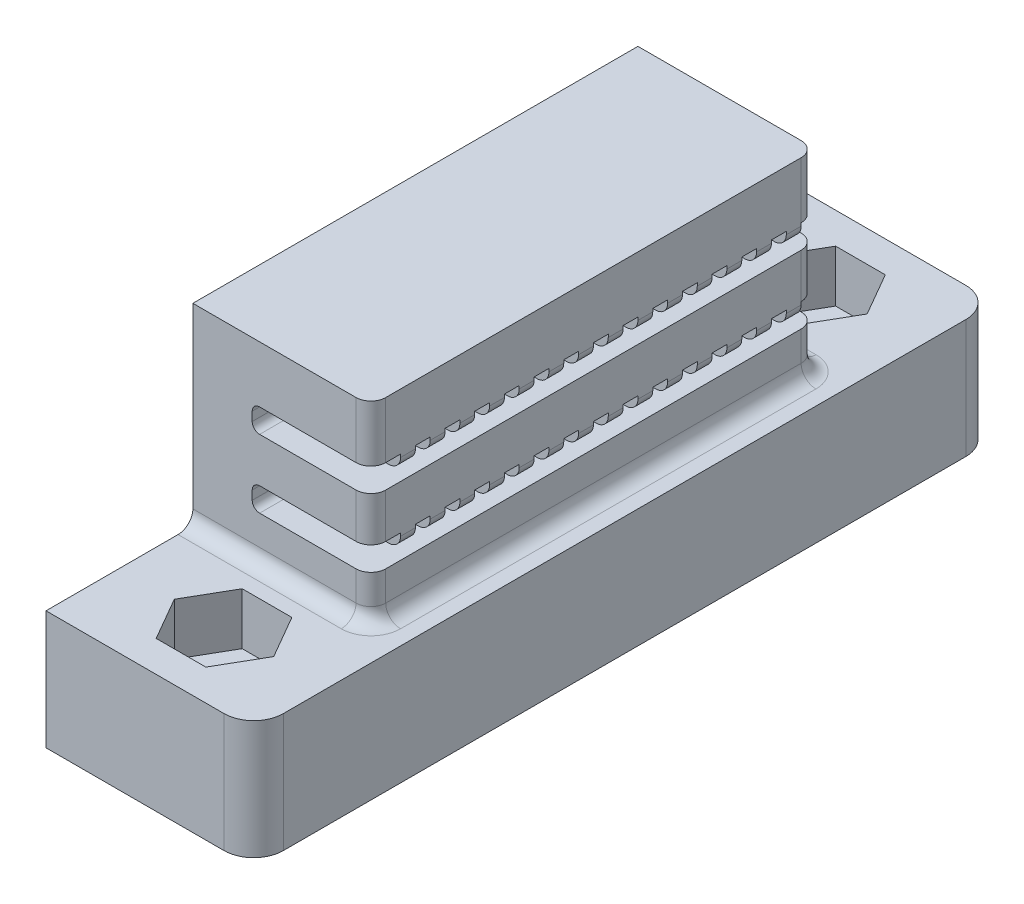
from build123d import *

# Parameters (mm, degrees)
CROQUIS1_W              = 14
CROQUIS1_H              = 50
CROQUIS1_R              = 1.55
SALIENTE_EXTRUIR1_DEPTH = 8
CORTAR_EXTRUIR1_DEPTH   = 3.5
CROQUIS3_W              = 14
CROQUIS3_H              = 30
SALIENTE_EXTRUIR3_DEPTH = 13
CORTAR_EXTRUIR2_DEPTH   = 10
CROQUIS5_W              = 30
CROQUIS5_H              = 13
CORTAR_EXTRUIR3_DEPTH   = 2
REDONDEO1_R             = 0.8
REDONDEO2_R             = 2
REDONDEO3_R             = 1
REDONDEO4_R             = 1
REDONDEO5_R             = 0.5


with BuildPart() as part:
    # Croquis1 → Saliente-Extruir1 (new body)
    with BuildSketch(Plane(origin=(0, 0, 0), x_dir=(1, 0, 0), z_dir=(0, 1, 0))):
        with Locations((7, 25)):
            Rectangle(CROQUIS1_W, CROQUIS1_H)
        with Locations((7, 45)):
            Circle(CROQUIS1_R, mode=Mode.SUBTRACT)
        with Locations((7, 5)):
            Circle(CROQUIS1_R, mode=Mode.SUBTRACT)
    extrude(amount=SALIENTE_EXTRUIR1_DEPTH)

    # Croquis2 → Cortar-Extruir1 (cut)
    with BuildSketch(Plane(origin=(0, 8, 0), x_dir=(1, 0, 0), z_dir=(0, 1, 0))):
        Polygon((10.348631561, 45), (8.674315781, 47.9), (5.325684219, 47.9), (3.651368439, 45), (5.325684219, 42.1), (8.674315781, 42.1), align=None)
        Polygon((10.348631561, 5), (8.674315781, 7.9), (5.325684219, 7.9), (3.651368439, 5), (5.325684219, 2.1), (8.674315781, 2.1), align=None)
    extrude(amount=-CORTAR_EXTRUIR1_DEPTH, mode=Mode.SUBTRACT)

    # Croquis3 → Saliente-Extruir3 (add)
    with BuildSketch(Plane(origin=(0, 8, 0), x_dir=(1, 0, 0), z_dir=(0, 1, 0))):
        with Locations((7, 24.9)):
            Rectangle(CROQUIS3_W, CROQUIS3_H)
    extrude(amount=SALIENTE_EXTRUIR3_DEPTH)

    # Croquis4 → Cortar-Extruir2 (cut)
    with BuildSketch(Plane(origin=(14, 0, 0), x_dir=(0, 0, -1), z_dir=(1, 0, 0))):
        Polygon((39.9, 17.2), (38.9, 17.2), (38.9, 16.2), (37.9, 16.2), (37.9, 17.2), (36.9, 17.2), (36.9, 16.2), (35.9, 16.2), (35.9, 17.2), (34.9, 17.2), (34.9, 16.2), (33.9, 16.2), (33.9, 17.2), (32.9, 17.2), (32.9, 16.2), (31.9, 16.2), (31.9, 17.2), (30.9, 17.2), (30.9, 16.2), (29.9, 16.2), (29.9, 17.2), (28.9, 17.2), (28.9, 16.2), (27.9, 16.2), (27.9, 17.2), (26.9, 17.2), (26.9, 16.2), (25.9, 16.2), (25.9, 17.2), (24.9, 17.2), (24.9, 16.2), (23.9, 16.2), (23.9, 17.2), (22.9, 17.2), (22.9, 16.2), (21.9, 16.2), (21.9, 17.2), (20.9, 17.2), (20.9, 16.2), (19.9, 16.2), (19.9, 17.2), (18.9, 17.2), (18.9, 16.2), (17.9, 16.2), (17.9, 17.2), (16.9, 17.2), (16.9, 16.2), (15.9, 16.2), (15.9, 17.2), (14.9, 17.2), (14.9, 16.2), (13.9, 16.2), (13.9, 17.2), (12.9, 17.2), (12.9, 16.2), (11.9, 16.2), (11.9, 17.2), (9.9, 17.2), (9.9, 15.6), (39.9, 15.6), align=None)
        Polygon((39.9, 12.6), (38.9, 12.6), (38.9, 11.6), (37.9, 11.6), (37.9, 12.6), (36.9, 12.6), (36.9, 11.6), (35.9, 11.6), (35.9, 12.6), (34.9, 12.6), (34.9, 11.6), (33.9, 11.6), (33.9, 12.6), (32.9, 12.6), (32.9, 11.6), (31.9, 11.6), (31.9, 12.6), (30.9, 12.6), (30.9, 11.6), (29.9, 11.6), (29.9, 12.6), (28.9, 12.6), (28.9, 11.6), (27.9, 11.6), (27.9, 12.6), (26.9, 12.6), (26.9, 11.6), (25.9, 11.6), (25.9, 12.6), (24.9, 12.6), (24.9, 11.6), (23.9, 11.6), (23.9, 12.6), (22.9, 12.6), (22.9, 11.6), (21.9, 11.6), (21.9, 12.6), (20.9, 12.6), (20.9, 11.6), (19.9, 11.6), (19.9, 12.6), (18.9, 12.6), (18.9, 11.6), (17.9, 11.6), (17.9, 12.6), (16.9, 12.6), (16.9, 11.6), (15.9, 11.6), (15.9, 12.6), (14.9, 12.6), (14.9, 11.6), (13.9, 11.6), (13.9, 12.6), (12.9, 12.6), (12.9, 11.6), (11.9, 11.6), (11.9, 12.6), (9.9, 12.6), (9.9, 11), (39.9, 11), align=None)
    extrude(amount=-CORTAR_EXTRUIR2_DEPTH, mode=Mode.SUBTRACT)

    # Croquis5 → Cortar-Extruir3 (cut)
    with BuildSketch(Plane(origin=(14, 0, 0), x_dir=(0, 0, -1), z_dir=(1, 0, 0))):
        with Locations((24.9, 14.5)):
            Rectangle(CROQUIS5_W, CROQUIS5_H)
    extrude(amount=-CORTAR_EXTRUIR3_DEPTH, mode=Mode.SUBTRACT)

    # Redondeo1
    redondeo1_edges = [part.edges().sort_by_distance(p)[0] for p in [
        (12, 11.6, -12.4),
        (12, 11.6, -14.4),
        (12, 11.6, -16.4),
        (12, 11.6, -18.4),
        (12, 11.6, -20.4),
        (12, 11.6, -22.4),
        (12, 11.6, -24.4),
        (12, 11.6, -26.4),
        (12, 11.6, -28.4),
        (12, 11.6, -30.4),
        (12, 11.6, -32.4),
        (12, 11.6, -34.4),
        (12, 11.6, -36.4),
        (12, 11.6, -38.4),
        (12, 16.2, -12.4),
        (12, 16.2, -14.4),
        (12, 16.2, -16.4),
        (12, 16.2, -18.4),
        (12, 16.2, -20.4),
        (12, 16.2, -22.4),
        (12, 16.2, -24.4),
        (12, 16.2, -26.4),
        (12, 16.2, -28.4),
        (12, 16.2, -30.4),
        (12, 16.2, -32.4),
        (12, 16.2, -34.4),
        (12, 16.2, -36.4),
        (12, 16.2, -38.4),
    ]]
    fillet(redondeo1_edges, radius=REDONDEO1_R)

    # Redondeo2
    redondeo2_edges = [part.edges().sort_by_distance(p)[0] for p in [
        (14, 4, -50),
        (14, 4, 0),
    ]]
    fillet(redondeo2_edges, radius=REDONDEO2_R)

    # Redondeo3
    redondeo3_edges = [part.edges().sort_by_distance(p)[0] for p in [
        (12, 9.5, -9.9),
        (12, 14.1, -9.9),
        (12, 19.1, -9.9),
        (12, 9.5, -39.9),
        (12, 14.1, -39.9),
        (12, 19.1, -39.9),
    ]]
    fillet(redondeo3_edges, radius=REDONDEO3_R)

    # Redondeo4
    redondeo4_edges = [part.edges().sort_by_distance(p)[0] for p in [
        (5.5, 8, -9.9),
        (5.5, 8, -39.9),
        (12, 8, -24.9),
        (11.707106781, 8, -39.607106781),
        (11.707106781, 8, -10.192893219),
    ]]
    fillet(redondeo4_edges, radius=REDONDEO4_R)

    # Redondeo5
    redondeo5_edges = [part.edges().sort_by_distance(p)[0] for p in [
        (4, 15.6, -24.9),
        (4, 17.2, -10.9),
        (4, 17.2, -13.4),
        (4, 17.2, -15.4),
        (4, 17.2, -17.4),
        (4, 17.2, -19.4),
        (4, 17.2, -21.4),
        (4, 17.2, -23.4),
        (4, 17.2, -25.4),
        (4, 17.2, -27.4),
        (4, 17.2, -29.4),
        (4, 17.2, -31.4),
        (4, 17.2, -33.4),
        (4, 17.2, -35.4),
        (4, 17.2, -37.4),
        (4, 17.2, -39.4),
        (4, 11, -24.9),
        (4, 12.6, -10.9),
        (4, 12.6, -13.4),
        (4, 12.6, -15.4),
        (4, 12.6, -17.4),
        (4, 12.6, -19.4),
        (4, 12.6, -21.4),
        (4, 12.6, -23.4),
        (4, 12.6, -25.4),
        (4, 12.6, -27.4),
        (4, 12.6, -29.4),
        (4, 12.6, -31.4),
        (4, 12.6, -33.4),
        (4, 12.6, -35.4),
        (4, 12.6, -37.4),
        (4, 12.6, -39.4),
    ]]
    fillet(redondeo5_edges, radius=REDONDEO5_R)


solid = part.part
